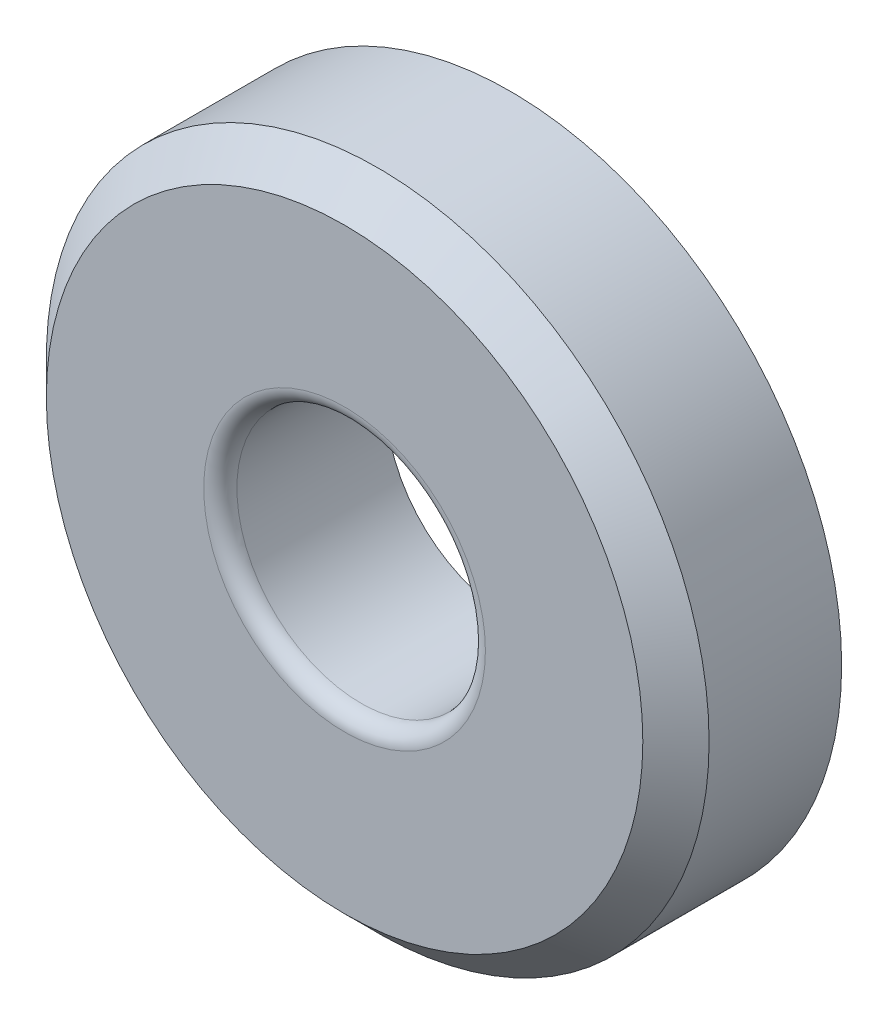
from build123d import *

# Parameters (mm, degrees)
IZIM1_R                     = 25.4
IZIM1_R_2                   = 9.525
Y_KSEKLIK_EKSTR_ZYON1_DEPTH = 12.7
PAH1_SIZE                   = 2.54
RADYUS1_R                   = 1.27


with BuildPart() as part:
    # Çizim1 → Yükseklik-Ekstrüzyon1 (new body)
    with BuildSketch(Plane.XY):
        Circle(IZIM1_R)
        Circle(IZIM1_R_2, mode=Mode.SUBTRACT)
    extrude(amount=Y_KSEKLIK_EKSTR_ZYON1_DEPTH)

    # Pah1
    pah1_edges = [part.edges().sort_by_distance(p)[0] for p in [
        (-25.4, 0, 12.7),
    ]]
    chamfer(pah1_edges, length=PAH1_SIZE)

    # Radyus1
    radyus1_edges = [part.edges().sort_by_distance(p)[0] for p in [
        (-9.525, 0, 12.7),
    ]]
    fillet(radyus1_edges, radius=RADYUS1_R)


solid = part.part
